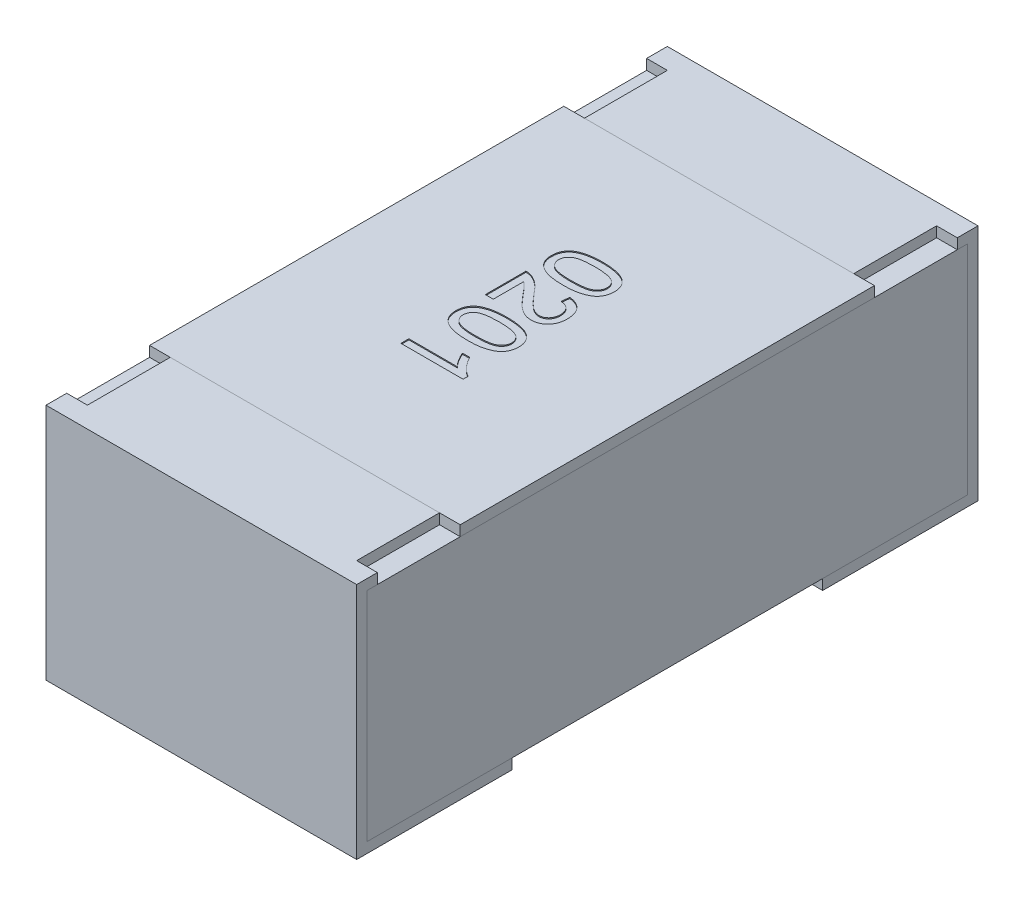
from build123d import *

# Parameters (mm, degrees)
BOSS_EXTRUDE2_DEPTH   = 0.15
BOSS_EXTRUDE2_2_DEPTH = 0.15
BOSS_EXTRUDE3_START   = -0.15
SKETCH5_W             = 0.58
SKETCH5_H             = 0.21
BOSS_EXTRUDE3_DEPTH   = 0.3
SKETCH6_W             = 0.02
SKETCH6_H             = 0.08
CUT_EXTRUDE1_DEPTH    = 0.01
SKETCH7_W             = 0.3
SKETCH7_H             = 0.4
BOSS_EXTRUDE4_DEPTH   = 0.01
TEXT0201_DEPTH        = 0.001


with BuildPart() as part:
    # Sketch4 → Boss-Extrude2 (new body, symmetric)
    with BuildSketch(Plane(origin=(0, 0, 0), x_dir=(0, 0, -1), z_dir=(1, 0, 0))):
        Polygon((-0.3, 0.115), (-0.3, -0.115), (-0.15, -0.115), (-0.15, -0.105), (-0.29, -0.105), (-0.29, 0.105), (-0.2, 0.105), (-0.2, 0.115), align=None)
    extrude(amount=BOSS_EXTRUDE2_DEPTH, both=True)


with BuildPart() as body_2:
    # Sketch4 → Boss-Extrude2 2 (new body, symmetric)
    with BuildSketch(Plane(origin=(0, 0, 0), x_dir=(0, 0, -1), z_dir=(1, 0, 0))):
        Polygon((0.2, 0.115), (0.3, 0.115), (0.3, -0.115), (0.15, -0.115), (0.15, -0.105), (0.29, -0.105), (0.29, 0.105), (0.2, 0.105), align=None)
    extrude(amount=BOSS_EXTRUDE2_2_DEPTH, both=True)


with BuildPart() as body_3:
    # Sketch5 → Boss-Extrude3 (new body)
    with BuildSketch(Plane(origin=(0, 0, 0), x_dir=(0, 0, -1), z_dir=(1, 0, 0)).offset(BOSS_EXTRUDE3_START)):
        Rectangle(SKETCH5_W, SKETCH5_H)
    extrude(amount=BOSS_EXTRUDE3_DEPTH)


with BuildPart() as cut_extrude1_tool:
    # Sketch6 → Cut-Extrude1 (new body)
    with BuildSketch(Plane(origin=(0, 0.115, 0), x_dir=(1, 0, 0), z_dir=(0, 1, 0))):
        with Locations((-0.14, 0.24)):
            Rectangle(SKETCH6_W, SKETCH6_H)
        with Locations((0.14, 0.24)):
            Rectangle(SKETCH6_W, SKETCH6_H)
        with Locations((0.14, -0.24)):
            Rectangle(SKETCH6_W, SKETCH6_H)
        with Locations((-0.14, -0.24)):
            Rectangle(SKETCH6_W, SKETCH6_H)
    extrude(amount=-CUT_EXTRUDE1_DEPTH)


with BuildPart() as part_1:
    add(part.part)

    # Cut-Extrude1: cut by cut_extrude1_tool
    add(cut_extrude1_tool.part, mode=Mode.SUBTRACT)


with BuildPart() as body_2_1:
    add(body_2.part)

    # Cut-Extrude1: cut by cut_extrude1_tool
    add(cut_extrude1_tool.part, mode=Mode.SUBTRACT)


with BuildPart() as body_4:
    # Sketch7 → Boss-Extrude4 (new body)
    with BuildSketch(Plane(origin=(0, 0.105, 0), x_dir=(1, 0, 0), z_dir=(0, 1, 0))):
        Rectangle(SKETCH7_W, SKETCH7_H)
    extrude(amount=BOSS_EXTRUDE4_DEPTH)

    # Sketch8 → TEXT0201 (cut)
    with BuildSketch(Plane(origin=(0, 0.115, 0), x_dir=(1, 0, 0), z_dir=(0, 1, 0))):
        with BuildLine():
            add(Edge.make_bspline(
                [(-0.000766954, 0.088461538), (9.0501e-05, 0.088453788), (0.001769895, 0.088438609), (0.004227149, 0.088344459), (0.006560701, 0.08818008), (0.008768526, 0.087934709), (0.010855604, 0.087644139), (0.012818967, 0.087266411), (0.014662983, 0.086841362), (0.01638586, 0.086331554), (0.018001958, 0.085770854), (0.019510261, 0.085136783), (0.020901847, 0.084417097), (0.022214508, 0.083676693), (0.023386755, 0.082814673), (0.024492838, 0.081940481), (0.02546962, 0.080964709), (0.026349073, 0.079933765), (0.027124893, 0.078830563), (0.027794397, 0.07766144), (0.028385503, 0.07643076), (0.028830492, 0.075115105), (0.029193251, 0.073741778), (0.029460101, 0.07230021), (0.029617418, 0.070788812), (0.029633515, 0.069755984), (0.0296417, 0.069230769)],
                knots=[0, 0, 0, 0, 2.572e-06, 5.038e-06, 7.376e-06, 9.589e-06, 1.1701e-05, 1.3696e-05, 1.5585e-05, 1.7376e-05, 1.9083e-05, 2.0715e-05, 2.2279e-05, 2.3782e-05, 2.5229e-05, 2.6639e-05, 2.8007e-05, 2.9363e-05, 3.07e-05, 3.2047e-05, 3.3402e-05, 3.4789e-05, 3.6206e-05, 3.766e-05, 3.9183e-05, 4.0758e-05, 4.0758e-05, 4.0758e-05, 4.0758e-05], degree=3))
            add(Edge.make_bspline(
                [(0.0296417, 0.069230769), (0.029619026, 0.068460225), (0.029574482, 0.066946459), (0.029211799, 0.064736119), (0.028589839, 0.06265391), (0.027757338, 0.060700159), (0.026680431, 0.058917111), (0.025404961, 0.05730507), (0.023877526, 0.05592917), (0.022148252, 0.05474396), (0.020213706, 0.053727642), (0.018092105, 0.052818505), (0.015774457, 0.052003378), (0.013705714, 0.051406741), (0.011916877, 0.050988445), (0.010438705, 0.050733775), (0.008848646, 0.050498641), (0.007142892, 0.050331974), (0.005329415, 0.050162378), (0.003400308, 0.050078646), (0.00135688, 0.050014746), (-4.5738e-05, 0.050005008), (-0.000766954, 0.05)],
                knots=[0, 0, 0, 0, 2.311e-06, 4.54e-06, 6.696e-06, 8.817e-06, 1.0893e-05, 1.2928e-05, 1.4961e-05, 1.7035e-05, 1.9202e-05, 2.1506e-05, 2.3954e-05, 2.6567e-05, 2.7961e-05, 2.9463e-05, 3.1066e-05, 3.2782e-05, 3.4604e-05, 3.6529e-05, 3.8573e-05, 4.0737e-05, 4.0737e-05, 4.0737e-05, 4.0737e-05], degree=3))
            add(Edge.make_bspline(
                [(-0.000766954, 0.05), (-0.001620388, 0.050007851), (-0.00328774, 0.050023191), (-0.005725197, 0.050115425), (-0.008041474, 0.050287573), (-0.010239394, 0.050509409), (-0.012320996, 0.050808084), (-0.014281185, 0.051181394), (-0.016122367, 0.051612567), (-0.017846396, 0.052100498), (-0.019455647, 0.052668171), (-0.020957821, 0.053308431), (-0.022367637, 0.053994979), (-0.023658838, 0.05477371), (-0.024852798, 0.055603106), (-0.025953277, 0.056490914), (-0.026944634, 0.057455524), (-0.027821197, 0.058496091), (-0.028610969, 0.059591418), (-0.02928656, 0.060763579), (-0.029850173, 0.062009834), (-0.030321234, 0.063319075), (-0.030679231, 0.064699992), (-0.030945034, 0.066145389), (-0.031103795, 0.067664696), (-0.03111951, 0.068701543), (-0.031127531, 0.069230769)],
                knots=[0, 0, 0, 0, 2.56e-06, 5.002e-06, 7.316e-06, 9.527e-06, 1.1628e-05, 1.3622e-05, 1.5512e-05, 1.73e-05, 1.8995e-05, 2.0627e-05, 2.2197e-05, 2.3695e-05, 2.5145e-05, 2.6555e-05, 2.7932e-05, 2.9288e-05, 3.0632e-05, 3.1978e-05, 3.3339e-05, 3.473e-05, 3.6147e-05, 3.7614e-05, 3.9136e-05, 4.0723e-05, 4.0723e-05, 4.0723e-05, 4.0723e-05], degree=3))
            add(Edge.make_bspline(
                [(-0.031127531, 0.069230769), (-0.031107738, 0.069924631), (-0.031069148, 0.071277471), (-0.030806954, 0.073253194), (-0.03034548, 0.075107515), (-0.029726579, 0.076856075), (-0.028898762, 0.078479219), (-0.027891562, 0.079984697), (-0.026728411, 0.081402761), (-0.025810711, 0.082219085), (-0.025346281, 0.082632212)],
                knots=[0, 0, 0, 0, 2.082e-06, 4.058e-06, 5.965e-06, 7.805e-06, 9.611e-06, 1.1415e-05, 1.3232e-05, 1.5094e-05, 1.5094e-05, 1.5094e-05, 1.5094e-05], degree=3))
            add(Edge.make_bspline(
                [(-0.025346281, 0.082632212), (-0.024660339, 0.08310773), (-0.023245898, 0.084088268), (-0.020834145, 0.085235903), (-0.018179143, 0.086259614), (-0.015228802, 0.08706304), (-0.012006603, 0.087692322), (-0.008506223, 0.088146821), (-0.004729175, 0.088404023), (-0.002117509, 0.088441934), (-0.000766954, 0.088461538)],
                knots=[0, 0, 0, 0, 2.5e-06, 5.156e-06, 7.986e-06, 1.103e-05, 1.4314e-05, 1.7829e-05, 2.1613e-05, 2.5664e-05, 2.5664e-05, 2.5664e-05, 2.5664e-05], degree=3))
        make_face()
        with BuildLine():
            add(Edge.make_bspline(
                [(-0.000742915, 0.080769231), (-0.001896934, 0.080761593), (-0.00410598, 0.080746972), (-0.007261983, 0.080594223), (-0.010109129, 0.080331272), (-0.012643476, 0.079983633), (-0.014868451, 0.079524609), (-0.016778384, 0.078948251), (-0.0183962, 0.078298557), (-0.019701847, 0.077494574), (-0.020766139, 0.076614301), (-0.021681465, 0.075705479), (-0.022459471, 0.074746727), (-0.023108169, 0.073744301), (-0.023599321, 0.072682647), (-0.023955309, 0.071573374), (-0.024160174, 0.070416241), (-0.02418961, 0.069628181), (-0.024204454, 0.069230769)],
                knots=[0, 0, 0, 0, 3.462e-06, 6.627e-06, 9.476e-06, 1.2037e-05, 1.4298e-05, 1.6283e-05, 1.8017e-05, 1.9512e-05, 2.0861e-05, 2.2153e-05, 2.3375e-05, 2.4559e-05, 2.5726e-05, 2.6874e-05, 2.8045e-05, 2.9237e-05, 2.9237e-05, 2.9237e-05, 2.9237e-05], degree=3))
            add(Edge.make_bspline(
                [(-0.024204454, 0.069230769), (-0.024189285, 0.068833457), (-0.024159207, 0.068045594), (-0.023958859, 0.066885787), (-0.023584545, 0.065780831), (-0.023095128, 0.06472076), (-0.022461215, 0.063711047), (-0.021680271, 0.062757004), (-0.020765488, 0.061843395), (-0.019688825, 0.060967076), (-0.018377143, 0.060169218), (-0.016760645, 0.059507337), (-0.014847366, 0.058939961), (-0.012623525, 0.058478418), (-0.010093185, 0.058129345), (-0.007253936, 0.057867984), (-0.004101993, 0.057714212), (-0.001896939, 0.057699833), (-0.000742915, 0.057692308)],
                knots=[0, 0, 0, 0, 1.192e-06, 2.364e-06, 3.516e-06, 4.682e-06, 5.86e-06, 7.082e-06, 8.373e-06, 9.732e-06, 1.1237e-05, 1.2961e-05, 1.4957e-05, 1.7218e-05, 1.9767e-05, 2.2616e-05, 2.5769e-05, 2.9231e-05, 2.9231e-05, 2.9231e-05, 2.9231e-05], degree=3))
            add(Edge.make_bspline(
                [(-0.000742915, 0.057692308), (0.000387097, 0.057699592), (0.002552157, 0.057713549), (0.005647359, 0.057871287), (0.008446721, 0.058118472), (0.010952801, 0.058456599), (0.01316295, 0.058905913), (0.015081653, 0.059451043), (0.01670549, 0.060100117), (0.018048704, 0.060873493), (0.019157482, 0.061730989), (0.02009851, 0.062642055), (0.020923164, 0.063589062), (0.021568885, 0.064626127), (0.02209847, 0.065709163), (0.022452991, 0.066861386), (0.02268052, 0.068067919), (0.022705736, 0.068893163), (0.022718623, 0.069314904)],
                knots=[0, 0, 0, 0, 3.39e-06, 6.495e-06, 9.295e-06, 1.1819e-05, 1.4077e-05, 1.6055e-05, 1.7796e-05, 1.9309e-05, 2.0689e-05, 2.1989e-05, 2.3234e-05, 2.4445e-05, 2.5644e-05, 2.6841e-05, 2.805e-05, 2.9315e-05, 2.9315e-05, 2.9315e-05, 2.9315e-05], degree=3))
            add(Edge.make_bspline(
                [(0.022718623, 0.069314904), (0.022708193, 0.069712291), (0.022687627, 0.070495887), (0.022491322, 0.071643175), (0.022163056, 0.072730446), (0.021718387, 0.073770157), (0.021119952, 0.074736352), (0.020421235, 0.075667348), (0.019569928, 0.076519541), (0.018933503, 0.077033065), (0.018608046, 0.077295673)],
                knots=[0, 0, 0, 0, 1.191e-06, 2.349e-06, 3.479e-06, 4.593e-06, 5.731e-06, 6.88e-06, 8.078e-06, 9.332e-06, 9.332e-06, 9.332e-06, 9.332e-06], degree=3))
            add(Edge.make_bspline(
                [(0.018608046, 0.077295673), (0.018130051, 0.077581573), (0.017120624, 0.078185333), (0.0153662, 0.078860906), (0.013361227, 0.07945768), (0.011074858, 0.079949023), (0.008511014, 0.080304475), (0.005672672, 0.080585091), (0.002555871, 0.08073086), (0.000387018, 0.080756088), (-0.000742915, 0.080769231)],
                knots=[0, 0, 0, 0, 1.668e-06, 3.523e-06, 5.618e-06, 7.943e-06, 1.053e-05, 1.338e-05, 1.6497e-05, 1.9887e-05, 1.9887e-05, 1.9887e-05, 1.9887e-05], degree=3))
        make_face(mode=Mode.SUBTRACT)
        with BuildLine():
            Line((-0.022665992, 0.004615385), (-0.0303583, 0.004615385))
            Line((-0.0303583, 0.004615385), (-0.0303583, 0.043846154))
            add(Edge.make_bspline(
                [(-0.0303583, 0.043846154), (-0.029901124, 0.043846957), (-0.028988306, 0.043848561), (-0.027638305, 0.043694097), (-0.026306213, 0.043452176), (-0.025451996, 0.043178636), (-0.025021761, 0.043040865)],
                knots=[0, 0, 0, 0, 1.37e-06, 2.736e-06, 4.07e-06, 5.424e-06, 5.424e-06, 5.424e-06, 5.424e-06], degree=3))
            add(Edge.make_bspline(
                [(-0.025021761, 0.043040865), (-0.024318963, 0.042786062), (-0.02288795, 0.042267241), (-0.020818472, 0.041220122), (-0.018773724, 0.039968014), (-0.017097048, 0.038769719), (-0.01576726, 0.037666088), (-0.01471431, 0.036755997), (-0.013649995, 0.035730797), (-0.012555338, 0.034609179), (-0.011430275, 0.033397947), (-0.010269563, 0.032097151), (-0.009095265, 0.030690935), (-0.008316874, 0.02970927), (-0.007918396, 0.029206731)],
                knots=[0, 0, 0, 0, 2.241e-06, 4.563e-06, 6.942e-06, 9.43e-06, 1.0737e-05, 1.2125e-05, 1.3605e-05, 1.5168e-05, 1.6827e-05, 1.8564e-05, 2.0398e-05, 2.2322e-05, 2.2322e-05, 2.2322e-05, 2.2322e-05], degree=3))
            add(Edge.make_bspline(
                [(-0.007918396, 0.029206731), (-0.007268594, 0.028434704), (-0.006017359, 0.026948119), (-0.004160642, 0.024848827), (-0.002436575, 0.022931465), (-0.000814941, 0.021226566), (0.000688533, 0.019720185), (0.002070439, 0.018408784), (0.003326464, 0.017281081), (0.004502073, 0.016350843), (0.005612175, 0.015565972), (0.00669501, 0.014900863), (0.007769494, 0.014346583), (0.008832227, 0.013884942), (0.009887754, 0.013519823), (0.010939149, 0.013270943), (0.011975981, 0.013102161), (0.0126659, 0.013085274), (0.013007085, 0.013076923)],
                knots=[0, 0, 0, 0, 3.027e-06, 5.829e-06, 8.407e-06, 1.0762e-05, 1.2887e-05, 1.4791e-05, 1.6477e-05, 1.7949e-05, 1.9286e-05, 2.0554e-05, 2.1758e-05, 2.291e-05, 2.4027e-05, 2.5103e-05, 2.6149e-05, 2.7171e-05, 2.7171e-05, 2.7171e-05, 2.7171e-05], degree=3))
            add(Edge.make_bspline(
                [(0.013007085, 0.013076923), (0.013344289, 0.013085275), (0.014005864, 0.013101661), (0.014974076, 0.013257132), (0.015906488, 0.013473561), (0.016786312, 0.01382346), (0.017639607, 0.014239944), (0.018439404, 0.014774188), (0.019205653, 0.015392193), (0.019918089, 0.016099776), (0.020586657, 0.016872546), (0.021141702, 0.017736296), (0.021645872, 0.018636199), (0.022039309, 0.019601996), (0.022342519, 0.020625086), (0.022553752, 0.021703828), (0.022690316, 0.022841101), (0.022709044, 0.023617386), (0.022718623, 0.024014423)],
                knots=[0, 0, 0, 0, 1.011e-06, 1.983e-06, 2.936e-06, 3.876e-06, 4.817e-06, 5.78e-06, 6.754e-06, 7.766e-06, 8.789e-06, 9.813e-06, 1.084e-05, 1.188e-05, 1.2933e-05, 1.4037e-05, 1.5174e-05, 1.6365e-05, 1.6365e-05, 1.6365e-05, 1.6365e-05], degree=3))
            add(Edge.make_bspline(
                [(0.022718623, 0.024014423), (0.022709028, 0.024431476), (0.022690249, 0.025247679), (0.022554041, 0.026440878), (0.022344707, 0.027573129), (0.022030063, 0.028640393), (0.021618137, 0.029640536), (0.021127164, 0.030580649), (0.020545305, 0.031457136), (0.0198695, 0.032255971), (0.019133354, 0.032995941), (0.018301012, 0.033621053), (0.017416277, 0.034167487), (0.016451059, 0.034598553), (0.015426562, 0.034950102), (0.014327575, 0.035203851), (0.013158813, 0.035342536), (0.012358384, 0.035370385), (0.011949392, 0.035384615)],
                knots=[0, 0, 0, 0, 1.251e-06, 2.448e-06, 3.598e-06, 4.701e-06, 5.779e-06, 6.839e-06, 7.879e-06, 8.928e-06, 9.974e-06, 1.1002e-05, 1.2043e-05, 1.3087e-05, 1.4166e-05, 1.5289e-05, 1.6464e-05, 1.7691e-05, 1.7691e-05, 1.7691e-05, 1.7691e-05], degree=3))
            Line((0.011949392, 0.035384615), (0.012718623, 0.043076923))
            add(Edge.make_bspline(
                [(0.012718623, 0.043076923), (0.013389032, 0.042998228), (0.014693256, 0.042845134), (0.016582106, 0.042463643), (0.018339643, 0.041928629), (0.019988689, 0.041286527), (0.021509071, 0.040487454), (0.022906337, 0.039561083), (0.024186871, 0.038508134), (0.025320892, 0.037310273), (0.026355973, 0.036013347), (0.027226838, 0.034585183), (0.02798143, 0.033058913), (0.028591587, 0.031423674), (0.029059105, 0.029680108), (0.029393383, 0.02783093), (0.029599685, 0.025874048), (0.029627495, 0.024531764), (0.0296417, 0.023846154)],
                knots=[0, 0, 0, 0, 2.025e-06, 3.939e-06, 5.771e-06, 7.53e-06, 9.24e-06, 1.0913e-05, 1.2552e-05, 1.4201e-05, 1.5853e-05, 1.7521e-05, 1.9209e-05, 2.0954e-05, 2.2748e-05, 2.4617e-05, 2.6587e-05, 2.8643e-05, 2.8643e-05, 2.8643e-05, 2.8643e-05], degree=3))
            add(Edge.make_bspline(
                [(0.0296417, 0.023846154), (0.029629815, 0.023152343), (0.029606663, 0.021800796), (0.029369912, 0.019831337), (0.029000886, 0.017973235), (0.028487567, 0.016219051), (0.027809633, 0.014578106), (0.026993124, 0.013044781), (0.026024003, 0.011623931), (0.024906511, 0.010334846), (0.023686025, 0.009172362), (0.022382891, 0.008155112), (0.021007647, 0.007299897), (0.019564265, 0.006592517), (0.018043408, 0.00605087), (0.016450778, 0.00567392), (0.014790249, 0.00541661), (0.013657132, 0.005395422), (0.0130792, 0.005384615)],
                knots=[0, 0, 0, 0, 2.081e-06, 4.053e-06, 5.941e-06, 7.759e-06, 9.527e-06, 1.1258e-05, 1.2962e-05, 1.4675e-05, 1.6367e-05, 1.8011e-05, 1.9625e-05, 2.1216e-05, 2.2824e-05, 2.4457e-05, 2.6121e-05, 2.7853e-05, 2.7853e-05, 2.7853e-05, 2.7853e-05], degree=3))
            add(Edge.make_bspline(
                [(0.0130792, 0.005384615), (0.01248538, 0.005400838), (0.011296428, 0.005433319), (0.009521547, 0.005696374), (0.007760572, 0.006119813), (0.005999508, 0.006707367), (0.004236822, 0.007525056), (0.002430187, 0.008532105), (0.00059298, 0.00979078), (-0.000980545, 0.01098443), (-0.002290383, 0.012108283), (-0.003370818, 0.013104443), (-0.004523258, 0.014256659), (-0.005770264, 0.015534289), (-0.007093399, 0.016963502), (-0.008512602, 0.018518254), (-0.009997815, 0.020229424), (-0.011012209, 0.02141754), (-0.011536185, 0.02203125)],
                knots=[0, 0, 0, 0, 1.781e-06, 3.566e-06, 5.37e-06, 7.21e-06, 9.125e-06, 1.1191e-05, 1.3408e-05, 1.58e-05, 1.7112e-05, 1.8584e-05, 2.0207e-05, 2.2001e-05, 2.394e-05, 2.605e-05, 2.8316e-05, 3.0737e-05, 3.0737e-05, 3.0737e-05, 3.0737e-05], degree=3))
            add(Edge.make_bspline(
                [(-0.011536185, 0.02203125), (-0.011964015, 0.022556789), (-0.012779823, 0.023558912), (-0.013962653, 0.024984512), (-0.015046819, 0.02626181), (-0.015998896, 0.027418977), (-0.016856839, 0.028416805), (-0.017603262, 0.029276695), (-0.018248664, 0.02999011), (-0.019238797, 0.031077673), (-0.020638342, 0.032465607), (-0.022008939, 0.033480037), (-0.022665992, 0.033966346)],
                knots=[0, 0, 0, 0, 2.033e-06, 3.877e-06, 5.557e-06, 7.059e-06, 8.372e-06, 9.505e-06, 1.0475e-05, 1.1258e-05, 1.3918e-05, 1.6368e-05, 1.6368e-05, 1.6368e-05, 1.6368e-05], degree=3))
            Line((-0.022665992, 0.033966346), (-0.022665992, 0.004615385))
        make_face()
        with BuildLine():
            add(Edge.make_bspline(
                [(-0.000766954, -0.003846154), (9.0501e-05, -0.003853904), (0.001769895, -0.003869083), (0.004227149, -0.003963233), (0.006560701, -0.004127612), (0.008768526, -0.004372984), (0.010855604, -0.004663554), (0.012818967, -0.005041282), (0.014662983, -0.00546633), (0.01638586, -0.005976139), (0.018001958, -0.006536838), (0.019510261, -0.007170909), (0.020901847, -0.007890595), (0.022214508, -0.008630999), (0.023386755, -0.009493019), (0.024492838, -0.010367211), (0.02546962, -0.011342983), (0.026349073, -0.012373927), (0.027124893, -0.013477129), (0.027794397, -0.014646253), (0.028385503, -0.015876932), (0.028830492, -0.017192587), (0.029193251, -0.018565914), (0.029460101, -0.020007482), (0.029617418, -0.02151888), (0.029633515, -0.022551708), (0.0296417, -0.023076923)],
                knots=[0, 0, 0, 0, 2.572e-06, 5.038e-06, 7.376e-06, 9.589e-06, 1.1701e-05, 1.3696e-05, 1.5585e-05, 1.7376e-05, 1.9083e-05, 2.0715e-05, 2.2279e-05, 2.3782e-05, 2.5229e-05, 2.6639e-05, 2.8007e-05, 2.9363e-05, 3.07e-05, 3.2047e-05, 3.3402e-05, 3.4789e-05, 3.6206e-05, 3.766e-05, 3.9183e-05, 4.0758e-05, 4.0758e-05, 4.0758e-05, 4.0758e-05], degree=3))
            add(Edge.make_bspline(
                [(0.0296417, -0.023076923), (0.029619026, -0.023847468), (0.029574482, -0.025361233), (0.029211799, -0.027571574), (0.028589839, -0.029653782), (0.027757338, -0.031607534), (0.026680431, -0.033390581), (0.025404961, -0.035002622), (0.023877526, -0.036378523), (0.022148252, -0.037563733), (0.020213706, -0.03858005), (0.018092105, -0.039489188), (0.015774457, -0.040304314), (0.013705714, -0.040900952), (0.011916877, -0.041319247), (0.010438705, -0.041573917), (0.008848646, -0.041809052), (0.007142892, -0.041975718), (0.005329415, -0.042145315), (0.003400308, -0.042229046), (0.00135688, -0.042292946), (-4.5738e-05, -0.042302685), (-0.000766954, -0.042307692)],
                knots=[0, 0, 0, 0, 2.311e-06, 4.54e-06, 6.696e-06, 8.817e-06, 1.0893e-05, 1.2928e-05, 1.4961e-05, 1.7035e-05, 1.9202e-05, 2.1506e-05, 2.3954e-05, 2.6567e-05, 2.7961e-05, 2.9463e-05, 3.1066e-05, 3.2782e-05, 3.4604e-05, 3.6529e-05, 3.8573e-05, 4.0737e-05, 4.0737e-05, 4.0737e-05, 4.0737e-05], degree=3))
            add(Edge.make_bspline(
                [(-0.000766954, -0.042307692), (-0.001620388, -0.042299841), (-0.00328774, -0.042284501), (-0.005725197, -0.042192267), (-0.008041474, -0.04202012), (-0.010239394, -0.041798283), (-0.012320996, -0.041499608), (-0.014281185, -0.041126298), (-0.016122367, -0.040695125), (-0.017846396, -0.040207194), (-0.019455647, -0.039639521), (-0.020957821, -0.038999261), (-0.022367637, -0.038312714), (-0.023658838, -0.037533982), (-0.024852798, -0.036704587), (-0.025953277, -0.035816779), (-0.026944634, -0.034852169), (-0.027821197, -0.033811602), (-0.028610969, -0.032716275), (-0.02928656, -0.031544113), (-0.029850173, -0.030297858), (-0.030321234, -0.028988617), (-0.030679231, -0.027607701), (-0.030945034, -0.026162304), (-0.031103795, -0.024642996), (-0.03111951, -0.02360615), (-0.031127531, -0.023076923)],
                knots=[0, 0, 0, 0, 2.56e-06, 5.002e-06, 7.316e-06, 9.527e-06, 1.1628e-05, 1.3622e-05, 1.5512e-05, 1.73e-05, 1.8995e-05, 2.0627e-05, 2.2197e-05, 2.3695e-05, 2.5145e-05, 2.6555e-05, 2.7932e-05, 2.9288e-05, 3.0632e-05, 3.1978e-05, 3.3339e-05, 3.473e-05, 3.6147e-05, 3.7614e-05, 3.9136e-05, 4.0723e-05, 4.0723e-05, 4.0723e-05, 4.0723e-05], degree=3))
            add(Edge.make_bspline(
                [(-0.031127531, -0.023076923), (-0.031107738, -0.022383061), (-0.031069148, -0.021030221), (-0.030806954, -0.019054498), (-0.03034548, -0.017200177), (-0.029726579, -0.015451617), (-0.028898762, -0.013828473), (-0.027891562, -0.012322995), (-0.026728411, -0.010904931), (-0.025810711, -0.010088607), (-0.025346281, -0.009675481)],
                knots=[0, 0, 0, 0, 2.082e-06, 4.058e-06, 5.965e-06, 7.805e-06, 9.611e-06, 1.1415e-05, 1.3232e-05, 1.5094e-05, 1.5094e-05, 1.5094e-05, 1.5094e-05], degree=3))
            add(Edge.make_bspline(
                [(-0.025346281, -0.009675481), (-0.024660339, -0.009199963), (-0.023245898, -0.008219424), (-0.020834145, -0.007071789), (-0.018179143, -0.006048078), (-0.015228802, -0.005244653), (-0.012006603, -0.00461537), (-0.008506223, -0.004160871), (-0.004729175, -0.00390367), (-0.002117509, -0.003865759), (-0.000766954, -0.003846154)],
                knots=[0, 0, 0, 0, 2.5e-06, 5.156e-06, 7.986e-06, 1.103e-05, 1.4314e-05, 1.7829e-05, 2.1613e-05, 2.5664e-05, 2.5664e-05, 2.5664e-05, 2.5664e-05], degree=3))
        make_face()
        with BuildLine():
            add(Edge.make_bspline(
                [(-0.000742915, -0.011538462), (-0.001896934, -0.011546099), (-0.00410598, -0.01156072), (-0.007261983, -0.011713469), (-0.010109129, -0.01197642), (-0.012643476, -0.012324059), (-0.014868451, -0.012783083), (-0.016778384, -0.013359442), (-0.0183962, -0.014009135), (-0.019701847, -0.014813119), (-0.020766139, -0.015693392), (-0.021681465, -0.016602213), (-0.022459471, -0.017560965), (-0.023108169, -0.018563391), (-0.023599321, -0.019625045), (-0.023955309, -0.020734318), (-0.024160174, -0.021891451), (-0.02418961, -0.022679511), (-0.024204454, -0.023076923)],
                knots=[0, 0, 0, 0, 3.462e-06, 6.627e-06, 9.476e-06, 1.2037e-05, 1.4298e-05, 1.6283e-05, 1.8017e-05, 1.9512e-05, 2.0861e-05, 2.2153e-05, 2.3375e-05, 2.4559e-05, 2.5726e-05, 2.6874e-05, 2.8045e-05, 2.9237e-05, 2.9237e-05, 2.9237e-05, 2.9237e-05], degree=3))
            add(Edge.make_bspline(
                [(-0.024204454, -0.023076923), (-0.024189285, -0.023474236), (-0.024159207, -0.024262098), (-0.023958859, -0.025421905), (-0.023584545, -0.026526862), (-0.023095128, -0.027586933), (-0.022461215, -0.028596645), (-0.021680271, -0.029550688), (-0.020765488, -0.030464297), (-0.019688825, -0.031340616), (-0.018377143, -0.032138474), (-0.016760645, -0.032800355), (-0.014847366, -0.033367732), (-0.012623525, -0.033829274), (-0.010093185, -0.034178347), (-0.007253936, -0.034439709), (-0.004101993, -0.03459348), (-0.001896939, -0.034607859), (-0.000742915, -0.034615385)],
                knots=[0, 0, 0, 0, 1.192e-06, 2.364e-06, 3.516e-06, 4.682e-06, 5.86e-06, 7.082e-06, 8.373e-06, 9.732e-06, 1.1237e-05, 1.2961e-05, 1.4957e-05, 1.7218e-05, 1.9767e-05, 2.2616e-05, 2.5769e-05, 2.9231e-05, 2.9231e-05, 2.9231e-05, 2.9231e-05], degree=3))
            add(Edge.make_bspline(
                [(-0.000742915, -0.034615385), (0.000387097, -0.0346081), (0.002552157, -0.034594144), (0.005647359, -0.034436405), (0.008446721, -0.034189221), (0.010952801, -0.033851093), (0.01316295, -0.033401779), (0.015081653, -0.03285665), (0.01670549, -0.032207575), (0.018048704, -0.031434199), (0.019157482, -0.030576704), (0.02009851, -0.029665637), (0.020923164, -0.02871863), (0.021568885, -0.027681565), (0.02209847, -0.02659853), (0.022452991, -0.025446307), (0.02268052, -0.024239773), (0.022705736, -0.02341453), (0.022718623, -0.022992788)],
                knots=[0, 0, 0, 0, 3.39e-06, 6.495e-06, 9.295e-06, 1.1819e-05, 1.4077e-05, 1.6055e-05, 1.7796e-05, 1.9309e-05, 2.0689e-05, 2.1989e-05, 2.3234e-05, 2.4445e-05, 2.5644e-05, 2.6841e-05, 2.805e-05, 2.9315e-05, 2.9315e-05, 2.9315e-05, 2.9315e-05], degree=3))
            add(Edge.make_bspline(
                [(0.022718623, -0.022992788), (0.022708193, -0.022595401), (0.022687627, -0.021811805), (0.022491322, -0.020664517), (0.022163056, -0.019577246), (0.021718387, -0.018537535), (0.021119952, -0.01757134), (0.020421235, -0.016640344), (0.019569928, -0.015788151), (0.018933503, -0.015274627), (0.018608046, -0.015012019)],
                knots=[0, 0, 0, 0, 1.191e-06, 2.349e-06, 3.479e-06, 4.593e-06, 5.731e-06, 6.88e-06, 8.078e-06, 9.332e-06, 9.332e-06, 9.332e-06, 9.332e-06], degree=3))
            add(Edge.make_bspline(
                [(0.018608046, -0.015012019), (0.018130051, -0.014726119), (0.017120624, -0.014122359), (0.0153662, -0.013446787), (0.013361227, -0.012850013), (0.011074858, -0.01235867), (0.008511014, -0.012003217), (0.005672672, -0.011722602), (0.002555871, -0.011576832), (0.000387018, -0.011551605), (-0.000742915, -0.011538462)],
                knots=[0, 0, 0, 0, 1.668e-06, 3.523e-06, 5.618e-06, 7.943e-06, 1.053e-05, 1.338e-05, 1.6497e-05, 1.9887e-05, 1.9887e-05, 1.9887e-05, 1.9887e-05], degree=3))
        make_face(mode=Mode.SUBTRACT)
        with BuildLine():
            Line((-0.0303583, -0.076923077), (-0.0303583, -0.069230769))
            Line((-0.0303583, -0.069230769), (0.016396508, -0.069230769))
            add(Edge.make_bspline(
                [(0.016396508, -0.069230769), (0.015969402, -0.06878782), (0.015081709, -0.067867199), (0.013824613, -0.066311507), (0.012556029, -0.064575536), (0.011319581, -0.062688085), (0.010178399, -0.060749298), (0.009137083, -0.058881385), (0.008260411, -0.057110437), (0.007780594, -0.055944223), (0.007550354, -0.055384615)],
                knots=[0, 0, 0, 0, 1.845e-06, 3.835e-06, 5.994e-06, 8.294e-06, 1.0601e-05, 1.2742e-05, 1.4709e-05, 1.6524e-05, 1.6524e-05, 1.6524e-05, 1.6524e-05], degree=3))
            Line((0.007550354, -0.055384615), (0.0146417, -0.055384615))
            add(Edge.make_bspline(
                [(0.0146417, -0.055384615), (0.015136732, -0.056345839), (0.016112412, -0.058240355), (0.017797544, -0.060916896), (0.019624297, -0.063415735), (0.021592266, -0.065695506), (0.023603884, -0.067739176), (0.025633685, -0.069461406), (0.027607266, -0.070902458), (0.028983619, -0.071625462), (0.0296417, -0.071971154)],
                knots=[0, 0, 0, 0, 3.242e-06, 6.391e-06, 9.477e-06, 1.252e-05, 1.5418e-05, 1.807e-05, 2.0501e-05, 2.2728e-05, 2.2728e-05, 2.2728e-05, 2.2728e-05], degree=3))
            Line((0.0296417, -0.071971154), (0.0296417, -0.076923077))
            Line((0.0296417, -0.076923077), (-0.0303583, -0.076923077))
        make_face()
    extrude(amount=-TEXT0201_DEPTH, mode=Mode.SUBTRACT)


solid = Compound([body_3.part, part_1.part, body_2_1.part, body_4.part])
